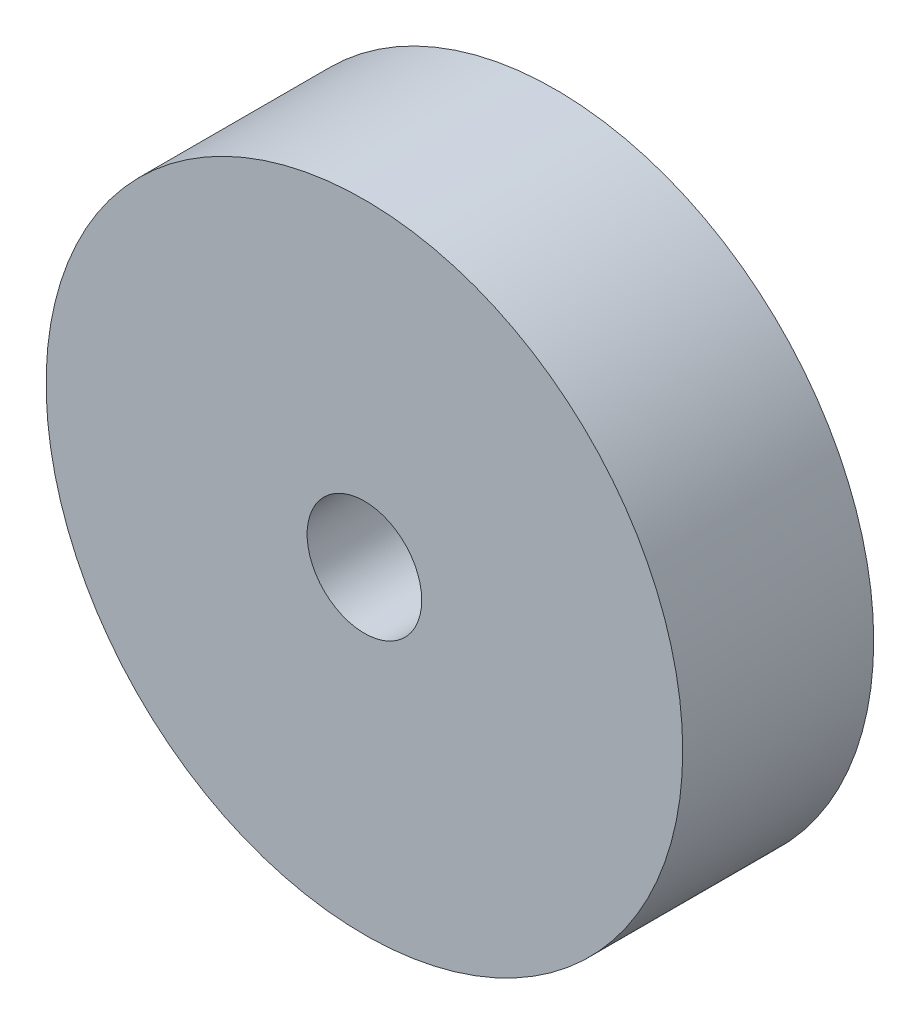
from build123d import *

# Parameters (mm, degrees)
CROQUIS1_R              = 5
CROQUIS1_R_2            = 0.9
SALIENTE_EXTRUIR1_DEPTH = 3


with BuildPart() as part:
    # Croquis1 → Saliente-Extruir1 (new body)
    with BuildSketch(Plane.XY):
        Circle(CROQUIS1_R)
        Circle(CROQUIS1_R_2, mode=Mode.SUBTRACT)
    extrude(amount=SALIENTE_EXTRUIR1_DEPTH)


solid = part.part
